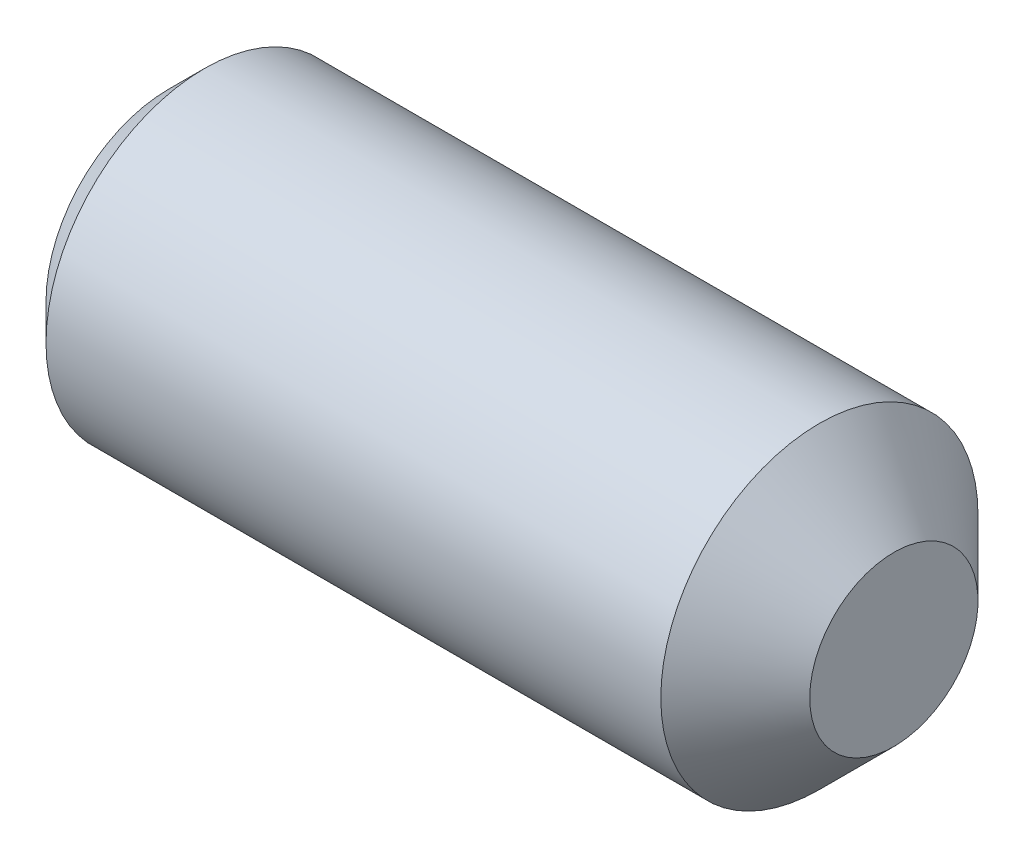
from build123d import *

# Parameters (mm, degrees)
HEX_2_DEPTH = 2.286


with BuildPart() as part:
    # BodySke → BaseBody (revolve)
    with BuildSketch(Plane.XY, mode=Mode.PRIVATE) as basebody_sk:
        Polygon((0, 0), (0, 1.61036), (0.47244, 2.0828), (8.5471, 2.0828), (9.525, 1.1049), (9.525, 0), align=None)
    revolve(basebody_sk.sketch.rotate(Axis((-12.7, 0, 0), (1, 0, 0)), 90), axis=Axis((-12.7, 0, 0), (1, 0, 0)))  # turned: the seam where the file's is

    # Sketch2 → Hex 2 (cut)
    with BuildSketch(Plane.ZY):
        Polygon((0.571923177, 0.9906), (-0.571923177, 0.9906), (-1.143846353, 0), (-0.571923177, -0.9906), (0.571923177, -0.9906), (1.143846353, 0), align=None)
    extrude(amount=-HEX_2_DEPTH, mode=Mode.SUBTRACT)


solid = part.part
